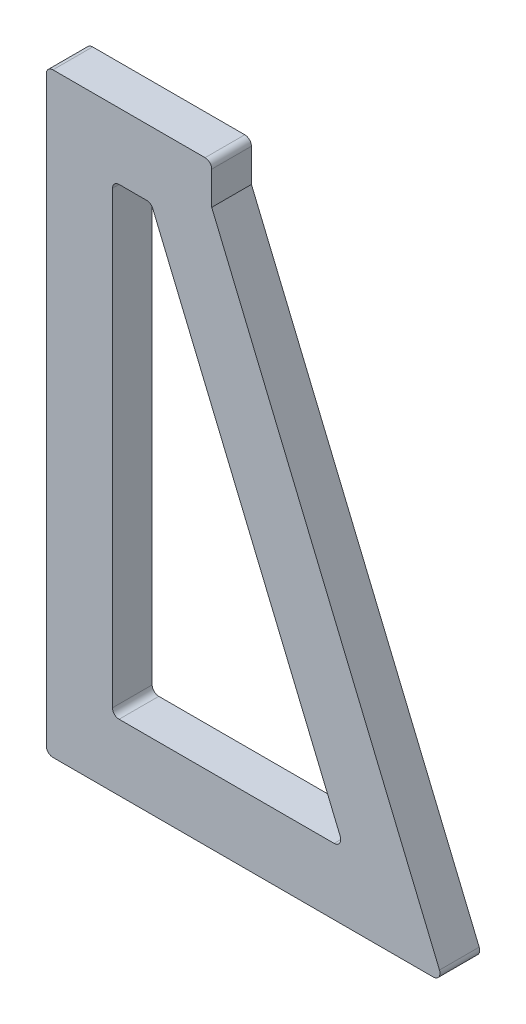
from build123d import *

# Parameters (mm, degrees)
BOSS_EXTRU_1_DEPTH = 6


with BuildPart() as part:
    # Esquisse1 → Boss.-Extru.1 (new body)
    with BuildSketch(Plane.XY):
        with BuildLine():
            Line((0, 1), (0, 89))
            ThreePointArc((0, 89), (0.292893219, 89.707106781), (1, 90))
            Line((1, 90), (24, 90))
            ThreePointArc((24, 90), (24.707106781, 89.707106781), (25, 89))
            Line((25, 89), (25, 84))
            Line((25, 84), (59.423076923, 1.384615385))
            ThreePointArc((59.423076923, 1.384615385), (59.332050294, 0.445299804), (58.5, 0))
            Line((58.5, 0), (1, 0))
            ThreePointArc((1, 0), (0.292893219, 0.292893219), (0, 1))
        make_face()
        with BuildLine():
            Line((10, 11), (10, 79))
            ThreePointArc((10, 79), (10.292893219, 79.707106781), (11, 80))
            Line((11, 80), (15.166666667, 80))
            ThreePointArc((15.166666667, 80), (15.721366863, 79.832050294), (16.08974359, 79.384615385))
            Line((16.08974359, 79.384615385), (44.423076923, 11.384615385))
            ThreePointArc((44.423076923, 11.384615385), (44.332050294, 10.445299804), (43.5, 10))
            Line((43.5, 10), (11, 10))
            ThreePointArc((11, 10), (10.292893219, 10.292893219), (10, 11))
        make_face(mode=Mode.SUBTRACT)
    extrude(amount=BOSS_EXTRU_1_DEPTH)


solid = part.part
